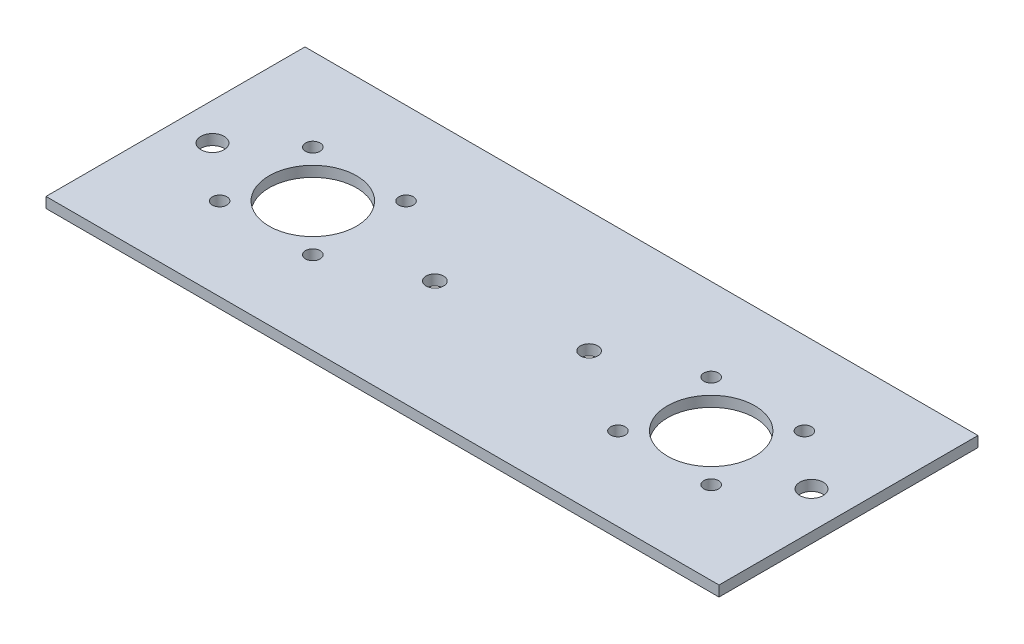
from build123d import *

# Parameters (mm, degrees)
SKETCH1_W           = 231.05
SKETCH1_H           = 88.9
SKETCH1_R           = 15
SKETCH1_R_2         = 2.5
SKETCH1_R_3         = 3
SKETCH1_R_4         = 4
BOSS_EXTRUDE1_DEPTH = 3.6


with BuildPart() as part:
    # Sketch1 → Boss-Extrude1 (new body)
    with BuildSketch(Plane(origin=(0, 0, 0), x_dir=(1, 0, 0), z_dir=(0, 1, 0))):
        with Locations((-115.525, 0)):
            Rectangle(SKETCH1_W, SKETCH1_H)
        with Locations((-183.9, 0)):
            Circle(SKETCH1_R, mode=Mode.SUBTRACT)
        with Locations((-47.15, 0)):
            Circle(SKETCH1_R, mode=Mode.SUBTRACT)
        with Locations((-63.15, -16)):
            Circle(SKETCH1_R_2, mode=Mode.SUBTRACT)
        with Locations((-31.15, -16)):
            Circle(SKETCH1_R_2, mode=Mode.SUBTRACT)
        with Locations((-31.15, 16)):
            Circle(SKETCH1_R_2, mode=Mode.SUBTRACT)
        with Locations((-63.15, 16)):
            Circle(SKETCH1_R_2, mode=Mode.SUBTRACT)
        with Locations((-167.9, 16)):
            Circle(SKETCH1_R_2, mode=Mode.SUBTRACT)
        with Locations((-199.9, 16)):
            Circle(SKETCH1_R_2, mode=Mode.SUBTRACT)
        with Locations((-199.9, -16)):
            Circle(SKETCH1_R_2, mode=Mode.SUBTRACT)
        with Locations((-167.9, -16)):
            Circle(SKETCH1_R_2, mode=Mode.SUBTRACT)
        with Locations((-139.15, -2.858987694)):
            Circle(SKETCH1_R_3, mode=Mode.SUBTRACT)
        with Locations((-91.9, 2.858987694)):
            Circle(SKETCH1_R_3, mode=Mode.SUBTRACT)
        with Locations((-218.35, 0)):
            Circle(SKETCH1_R_4, mode=Mode.SUBTRACT)
        with Locations((-12.7, 0)):
            Circle(SKETCH1_R_4, mode=Mode.SUBTRACT)
    extrude(amount=-BOSS_EXTRUDE1_DEPTH)


solid = part.part
